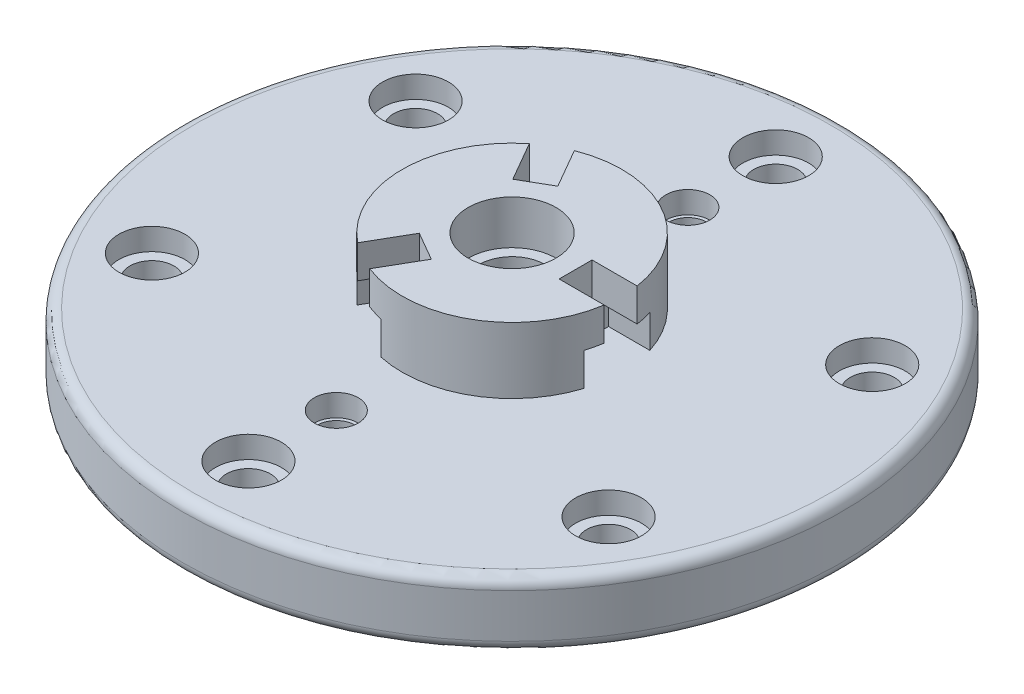
from build123d import *

# Parameters (mm, degrees)
SKETCH1_R           = 30
BOSS_EXTRUDE1_DEPTH = 50
SKETCH2_R           = 60
BOSS_EXTRUDE2_DEPTH = 20
SKETCH3_R           = 150
BOSS_EXTRUDE3_DEPTH = 30
SKETCH4_R           = 50
BOSS_EXTRUDE4_DEPTH = 30
SKETCH5_R           = 15
CUT_EXTRUDE1_DEPTH  = 131
SKETCH6_R           = 20
CUT_EXTRUDE2_DEPTH  = 20
SKETCH7_R           = 10
SKETCH7_R_2         = 15
CUT_EXTRUDE3_DEPTH  = 10
SKETCH7_3_R         = 10
CUT_EXTRUDE4_DEPTH  = 101
SKETCH8_R           = 8.5
CUT_EXTRUDE6_DEPTH  = 101
SKETCH8_3_R         = 10
SKETCH8_3_R_2       = 8.5
CUT_EXTRUDE7_DEPTH  = 10
SKETCH10_W          = 32.181548772
SKETCH10_H          = 15
CUT_EXTRUDE8_DEPTH  = 30
SKETCH11_W          = 24.632188436
SKETCH11_H          = 30
CUT_EXTRUDE9_DEPTH  = 15
CUT_EXTRUDE10_DEPTH = 40
FILLET1_R           = 5


with BuildPart() as part:
    # Sketch1 → Boss-Extrude1 (new body)
    with BuildSketch(Plane(origin=(0, 0, 0), x_dir=(1, 0, 0), z_dir=(0, 1, 0))):
        Circle(SKETCH1_R)
    extrude(amount=BOSS_EXTRUDE1_DEPTH)

    # Sketch2 → Boss-Extrude2 (add)
    with BuildSketch(Plane(origin=(0, 50, 0), x_dir=(1, 0, 0), z_dir=(0, 1, 0))):
        Circle(SKETCH2_R)
    extrude(amount=BOSS_EXTRUDE2_DEPTH)

    # Sketch3 → Boss-Extrude3 (add)
    with BuildSketch(Plane(origin=(0, 70, 0), x_dir=(1, 0, 0), z_dir=(0, 1, 0))):
        Circle(SKETCH3_R)
    extrude(amount=BOSS_EXTRUDE3_DEPTH)

    # Sketch4 → Boss-Extrude4 (add)
    with BuildSketch(Plane(origin=(0, 100, 0), x_dir=(1, 0, 0), z_dir=(0, 1, 0))):
        Circle(SKETCH4_R)
    extrude(amount=BOSS_EXTRUDE4_DEPTH)

    # Sketch5 → Cut-Extrude1 (cut, through all)
    with BuildSketch(Plane(origin=(0, 130, 0), x_dir=(1, 0, 0), z_dir=(0, 1, 0))):
        Circle(SKETCH5_R)
    extrude(amount=-CUT_EXTRUDE1_DEPTH, mode=Mode.SUBTRACT)

    # Sketch6 → Cut-Extrude2 (cut)
    with BuildSketch(Plane(origin=(0, 130, 0), x_dir=(1, 0, 0), z_dir=(0, 1, 0))):
        Circle(SKETCH6_R)
    extrude(amount=-CUT_EXTRUDE2_DEPTH, mode=Mode.SUBTRACT)

    # Sketch7 → Cut-Extrude3 (cut)
    with BuildSketch(Plane(origin=(0, 100, 0), x_dir=(1, 0, 0), z_dir=(0, 1, 0))):
        with Locations((-103.923048454, -60)):
            Circle(SKETCH7_R)
        with Locations((-103.923048454, -60)):
            Circle(SKETCH7_R_2)
        with Locations((-103.923048454, -60)):
            Circle(SKETCH7_R, mode=Mode.SUBTRACT)
        with Locations((-103.923048454, 60)):
            Circle(SKETCH7_R)
        with Locations((-103.923048454, 60)):
            Circle(SKETCH7_R_2)
        with Locations((-103.923048454, 60)):
            Circle(SKETCH7_R, mode=Mode.SUBTRACT)
        with Locations((0, 120)):
            Circle(SKETCH7_R)
        with Locations((0, 120)):
            Circle(SKETCH7_R_2)
        with Locations((0, 120)):
            Circle(SKETCH7_R, mode=Mode.SUBTRACT)
        with Locations((103.923048454, 60)):
            Circle(SKETCH7_R_2)
        with Locations((103.923048454, 60)):
            Circle(SKETCH7_R, mode=Mode.SUBTRACT)
        with Locations((103.923048454, 60)):
            Circle(SKETCH7_R)
        with Locations((103.923048454, -60)):
            Circle(SKETCH7_R_2)
        with Locations((103.923048454, -60)):
            Circle(SKETCH7_R, mode=Mode.SUBTRACT)
        with Locations((103.923048454, -60)):
            Circle(SKETCH7_R)
        with Locations((0, -120)):
            Circle(SKETCH7_R_2)
        with Locations((0, -120)):
            Circle(SKETCH7_R, mode=Mode.SUBTRACT)
        with Locations((0, -120)):
            Circle(SKETCH7_R)
    extrude(amount=-CUT_EXTRUDE3_DEPTH, mode=Mode.SUBTRACT)

    # Sketch7_3 → Cut-Extrude4 (cut, through all)
    with BuildSketch(Plane(origin=(0, 100, 0), x_dir=(1, 0, 0), z_dir=(0, 1, 0))):
        with Locations((-103.923048454, -60)):
            Circle(SKETCH7_3_R)
        with Locations((-103.923048454, 60)):
            Circle(SKETCH7_3_R)
        with Locations((0, 120)):
            Circle(SKETCH7_3_R)
        with Locations((103.923048454, 60)):
            Circle(SKETCH7_3_R)
        with Locations((103.923048454, -60)):
            Circle(SKETCH7_3_R)
        with Locations((0, -120)):
            Circle(SKETCH7_3_R)
    extrude(amount=-CUT_EXTRUDE4_DEPTH, mode=Mode.SUBTRACT)

    # Sketch8 → Cut-Extrude6 (cut, through all)
    with BuildSketch(Plane(origin=(0, 100, 0), x_dir=(1, 0, 0), z_dir=(0, 1, 0))):
        with Locations((0, -80)):
            Circle(SKETCH8_R)
        with Locations((0, 80)):
            Circle(SKETCH8_R)
    extrude(amount=-CUT_EXTRUDE6_DEPTH, mode=Mode.SUBTRACT)

    # Sketch8_3 → Cut-Extrude7 (cut)
    with BuildSketch(Plane(origin=(0, 100, 0), x_dir=(1, 0, 0), z_dir=(0, 1, 0))):
        with Locations((0, -80)):
            Circle(SKETCH8_3_R)
        with Locations((0, -80)):
            Circle(SKETCH8_3_R_2, mode=Mode.SUBTRACT)
        with Locations((0, 80)):
            Circle(SKETCH8_3_R)
        with Locations((0, 80)):
            Circle(SKETCH8_3_R_2, mode=Mode.SUBTRACT)
    extrude(amount=-CUT_EXTRUDE7_DEPTH, mode=Mode.SUBTRACT)

    # Sketch10 → Cut-Extrude8 (cut)
    with BuildSketch(Plane(origin=(0, 130, 0), x_dir=(1, 0, 0), z_dir=(0, 1, 0))):
        Polygon((-20.949803335, -21.286123785), (-7.959422279, -28.786123785), (-24.050196665, -56.656162555), (-37.040577721, -49.156162555), align=None)
        with Locations((45, 0)):
            Rectangle(SKETCH10_W, SKETCH10_H)
        Polygon((-7.959422279, 28.786123785), (-20.949803335, 21.286123785), (-37.040577721, 49.156162555), (-24.050196665, 56.656162555), align=None)
    extrude(amount=-CUT_EXTRUDE8_DEPTH, mode=Mode.SUBTRACT)

    # Sketch11 → Cut-Extrude9 (cut)
    with BuildSketch(Plane(origin=(0, 100, 0), x_dir=(1, 0, 0), z_dir=(0, 1, 0))):
        with Locations((41.225319832, 0)):
            Rectangle(SKETCH11_W, SKETCH11_H)
        Polygon((-27.444993864, -17.536123785), (-1.46423175, -32.536123785), (-13.780325968, -53.868224722), (-39.761088082, -38.868224722), align=None)
        Polygon((-1.46423175, 32.536123785), (-27.444993864, 17.536123785), (-39.761088082, 38.868224722), (-13.780325968, 53.868224722), align=None)
    extrude(amount=CUT_EXTRUDE9_DEPTH, mode=Mode.SUBTRACT)

    # Sketch12 → Cut-Extrude10 (cut)
    with BuildSketch(Plane.XZ):
        with BuildLine():
            Line((-28.75, -8.569568251), (-28.75, 8.569568251))
            ThreePointArc((-28.75, 8.569568251), (-30, 0), (-28.75, -8.569568251))
        make_face()
        with BuildLine():
            ThreePointArc((30, 0), (29.685855218, 4.330127019), (28.75, 8.569568251))
            Line((28.75, 8.569568251), (28.75, -8.569568251))
            ThreePointArc((28.75, -8.569568251), (29.685855218, -4.330127019), (30, 0))
        make_face()
    extrude(amount=-CUT_EXTRUDE10_DEPTH, mode=Mode.SUBTRACT)

    # Fillet1
    fillet1_edges = [part.edges().sort_by_distance(p)[0] for p in [
        (-150, 70, 0),
        (-150, 100, 0),
    ]]
    fillet(fillet1_edges, radius=FILLET1_R)


solid = part.part
